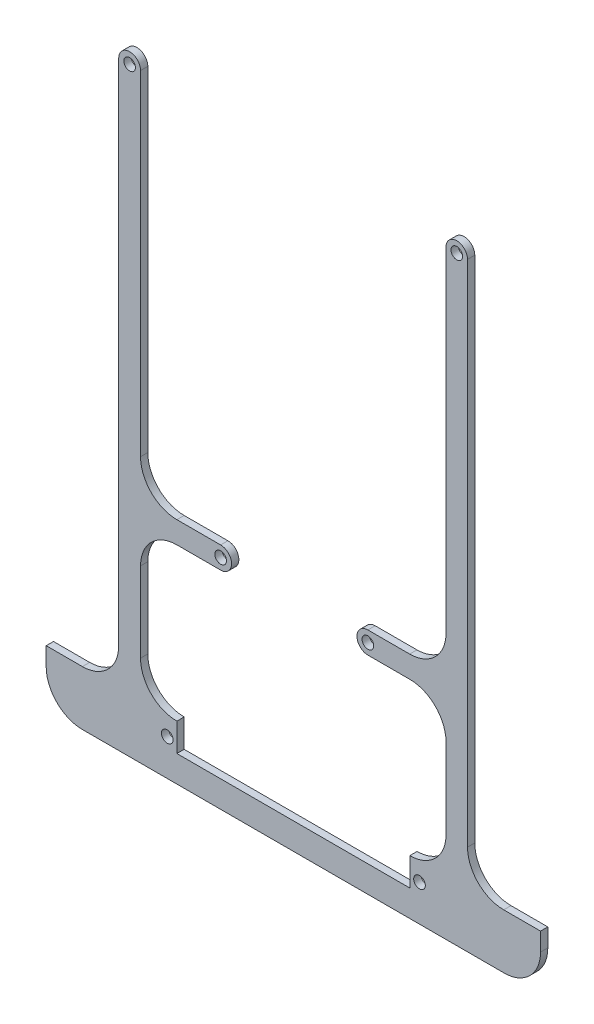
from build123d import *

# Parameters (mm, degrees)
SKETCH1_R           = 1.6
BOSS_EXTRUDE1_DEPTH = 2


with BuildPart() as part:
    # Sketch1 → Boss-Extrude1 (new body)
    with BuildSketch(Plane.XY):
        with BuildLine():
            Line((-48.044206104, 75), (-48.044206104, -65))
            ThreePointArc((-48.044206104, -65), (-50.973138292, -72.071067812), (-58.044206104, -75))
            Line((-58.044206104, -75), (-68, -75))
            Line((-68, -75), (-68, -80))
            ThreePointArc((-68, -80), (-65.071067812, -87.071067812), (-58, -90))
            Line((-58, -90), (58, -90))
            ThreePointArc((58, -90), (65.071067812, -87.071067812), (68, -80))
            Line((68, -80), (68, -75))
            Line((68, -75), (57.867381689, -75))
            ThreePointArc((57.867381689, -75), (50.827572313, -72.08401548), (47.911587793, -65.044206104))
            Line((47.911587793, -65.044206104), (47.911587793, 75))
            ThreePointArc((47.911587793, 75), (44.955793896, 77.955793896), (42, 75))
            Line((42, 75), (42, -17))
            ThreePointArc((42, -17), (39.071067812, -24.071067812), (32, -27))
            Line((32, -27), (20.5, -27))
            ThreePointArc((20.5, -27), (17.5, -30), (20.5, -33))
            Line((20.5, -33), (32.044206104, -33))
            ThreePointArc((32.044206104, -33), (39.08401548, -35.91598452), (42, -42.955793896))
            Line((42, -42.955793896), (42, -65.044206104))
            ThreePointArc((42, -65.044206104), (39.08401548, -72.08401548), (32.044206104, -75))
            Line((32.044206104, -75), (32.044206104, -82.72))
            Line((32.044206104, -82.72), (-32.044206104, -82.72))
            Line((-32.044206104, -82.72), (-32.044206104, -75))
            ThreePointArc((-32.044206104, -75), (-39.115273915, -72.071067812), (-42.044206104, -65))
            Line((-42.044206104, -65), (-42.044206104, -43))
            ThreePointArc((-42.044206104, -43), (-39.115273915, -35.928932188), (-32.044206104, -33))
            Line((-32.044206104, -33), (-20, -33))
            ThreePointArc((-20, -33), (-17, -30), (-20, -27))
            Line((-20, -27), (-32.044206104, -27))
            ThreePointArc((-32.044206104, -27), (-39.115273915, -24.071067812), (-42.044206104, -17))
            Line((-42.044206104, -17), (-42.044206104, 75))
            ThreePointArc((-42.044206104, 75), (-45.044206104, 78), (-48.044206104, 75))
        make_face()
        with Locations((-45.044206104, 75)):
            Circle(SKETCH1_R, mode=Mode.SUBTRACT)
        with Locations((44.955793896, 75)):
            Circle(SKETCH1_R, mode=Mode.SUBTRACT)
        with Locations((-34.7, -80)):
            Circle(SKETCH1_R, mode=Mode.SUBTRACT)
        with Locations((34.7, -80)):
            Circle(SKETCH1_R, mode=Mode.SUBTRACT)
        with Locations((-20, -30)):
            Circle(SKETCH1_R, mode=Mode.SUBTRACT)
        with Locations((20.5, -30)):
            Circle(SKETCH1_R, mode=Mode.SUBTRACT)
    extrude(amount=BOSS_EXTRUDE1_DEPTH)


solid = part.part
